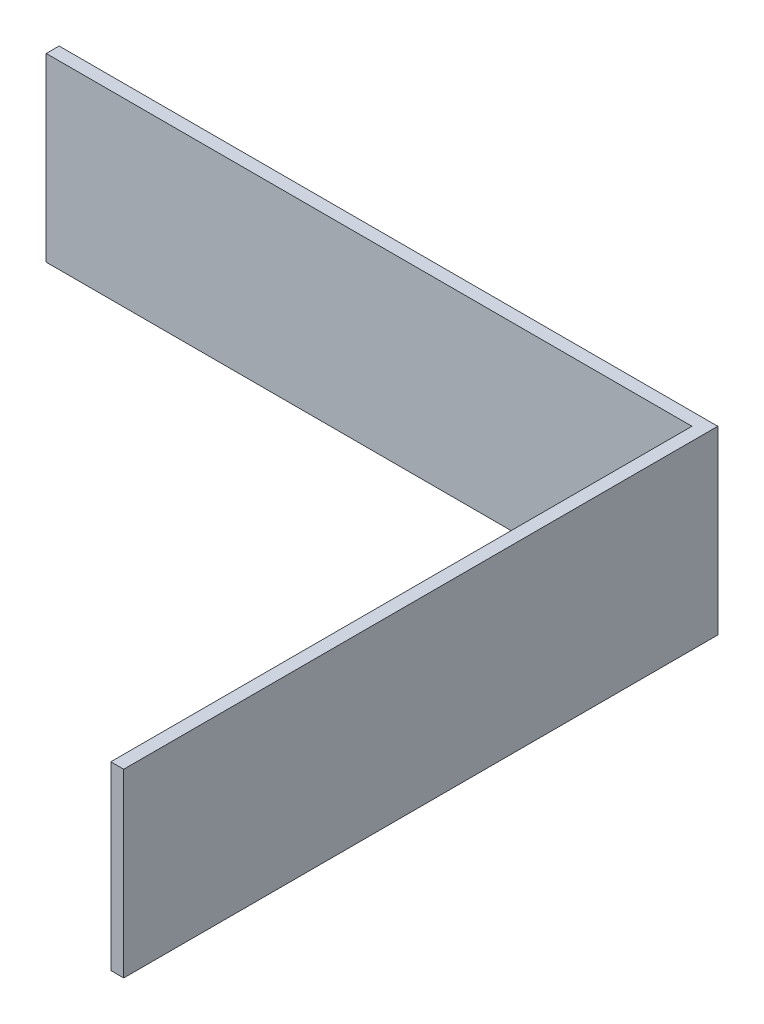
from build123d import *

# Parameters (mm, degrees)
BOSS_EXTRUDE1_DEPTH = 140


with BuildPart() as part:
    # Sketch1 → Boss-Extrude1 (new body)
    with BuildSketch(Plane(origin=(0, 0, 0), x_dir=(1, 0, 0), z_dir=(0, 1, 0))):
        Polygon((0, 0), (-500, 0), (-500, 10), (10, 10), (10, -450), (0, -450), align=None)
    extrude(amount=BOSS_EXTRUDE1_DEPTH)


solid = part.part
